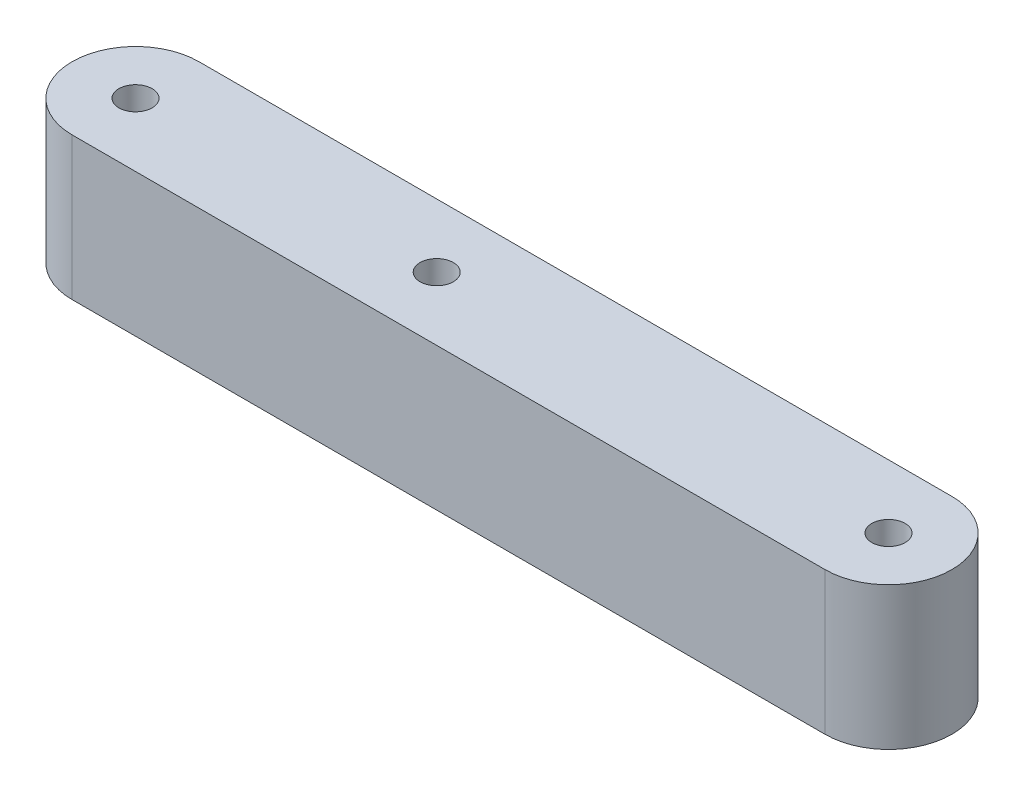
from build123d import *

# Parameters (mm, degrees)
EXTRUDE_1_DEPTH     = 9
SKETCH_3_R          = 1.05
CUT_EXTRUDE_1_DEPTH = 9


with BuildPart() as part:
    # 草图2 → 凸台-拉伸1 (new body)
    with BuildSketch(Plane(origin=(0, 0, 0), x_dir=(1, 0, 0), z_dir=(0, 1, 0))):
        with BuildLine():
            Line((0, 0), (47.5, 0))
            ThreePointArc((47.5, 0), (51.5, -4), (47.5, -8))
            Line((47.5, -8), (0, -8))
            ThreePointArc((0, -8), (-4, -4), (0, 0))
        make_face()
    extrude(amount=EXTRUDE_1_DEPTH)

    # 草图3 → 切除-拉伸1 (cut)
    with BuildSketch(Plane.XZ):
        with Locations((0, 4)):
            Circle(SKETCH_3_R)
        with Locations((19, 4)):
            Circle(SKETCH_3_R)
        with Locations((47.5, 4)):
            Circle(SKETCH_3_R)
    extrude(amount=-CUT_EXTRUDE_1_DEPTH, mode=Mode.SUBTRACT)


solid = part.part
